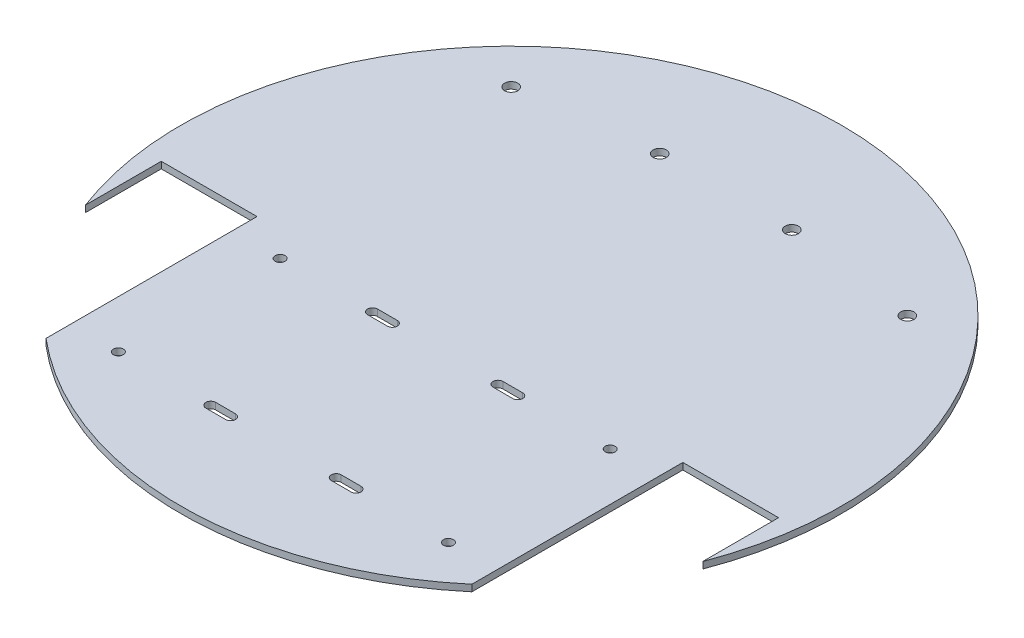
from build123d import *

# Parameters (mm, degrees)
SKETCH1_R           = 1.5
SKETCH1_R_2         = 2
BOSS_EXTRUDE1_DEPTH = 2


with BuildPart() as part:
    # Sketch1 → Boss-Extrude1 (new body)
    with BuildSketch(Plane(origin=(0, 0, 0), x_dir=(1, 0, 0), z_dir=(0, 1, 0))):
        with BuildLine():
            Line((-93.5, -35.464771253), (-93.5, -12.5))
            Line((-93.5, -12.5), (-64.5, -12.5))
            Line((-64.5, -12.5), (-64.5, -76.418256981))
            ThreePointArc((-64.5, -76.418256981), (0, -100), (64.5, -76.418256981))
            Line((64.5, -76.418256981), (64.5, -12.5))
            Line((64.5, -12.5), (93.5, -12.5))
            Line((93.5, -12.5), (93.5, -35.464771253))
            ThreePointArc((93.5, -35.464771253), (0, 100), (-93.5, -35.464771253))
        make_face()
        with Locations((-50, -69)):
            Circle(SKETCH1_R, mode=Mode.SUBTRACT)
        with BuildLine():
            Line((-22, -67.5), (-16, -67.5))
            ThreePointArc((-16, -67.5), (-14.5, -69), (-16, -70.5))
            Line((-16, -70.5), (-22, -70.5))
            ThreePointArc((-22, -70.5), (-23.5, -69), (-22, -67.5))
        make_face(mode=Mode.SUBTRACT)
        with Locations((-50, -20)):
            Circle(SKETCH1_R, mode=Mode.SUBTRACT)
        with BuildLine():
            ThreePointArc((-16, -18.5), (-14.5, -20), (-16, -21.5))
            Line((-16, -21.5), (-22, -21.5))
            ThreePointArc((-22, -21.5), (-23.5, -20), (-22, -18.5))
            Line((-22, -18.5), (-16, -18.5))
        make_face(mode=Mode.SUBTRACT)
        with BuildLine():
            ThreePointArc((16, -70.5), (14.5, -69), (16, -67.5))
            Line((16, -67.5), (22, -67.5))
            ThreePointArc((22, -67.5), (23.5, -69), (22, -70.5))
            Line((22, -70.5), (16, -70.5))
        make_face(mode=Mode.SUBTRACT)
        with Locations((50, -69)):
            Circle(SKETCH1_R, mode=Mode.SUBTRACT)
        with BuildLine():
            Line((22, -21.5), (16, -21.5))
            ThreePointArc((16, -21.5), (14.5, -20), (16, -18.5))
            Line((16, -18.5), (22, -18.5))
            ThreePointArc((22, -18.5), (23.5, -20), (22, -21.5))
        make_face(mode=Mode.SUBTRACT)
        with Locations((50, -20)):
            Circle(SKETCH1_R, mode=Mode.SUBTRACT)
        with Locations((-60, 60)):
            Circle(SKETCH1_R_2, mode=Mode.SUBTRACT)
        with Locations((-20, 65)):
            Circle(SKETCH1_R_2, mode=Mode.SUBTRACT)
        with Locations((20, 65)):
            Circle(SKETCH1_R_2, mode=Mode.SUBTRACT)
        with Locations((60, 60)):
            Circle(SKETCH1_R_2, mode=Mode.SUBTRACT)
    extrude(amount=BOSS_EXTRUDE1_DEPTH)


solid = part.part
